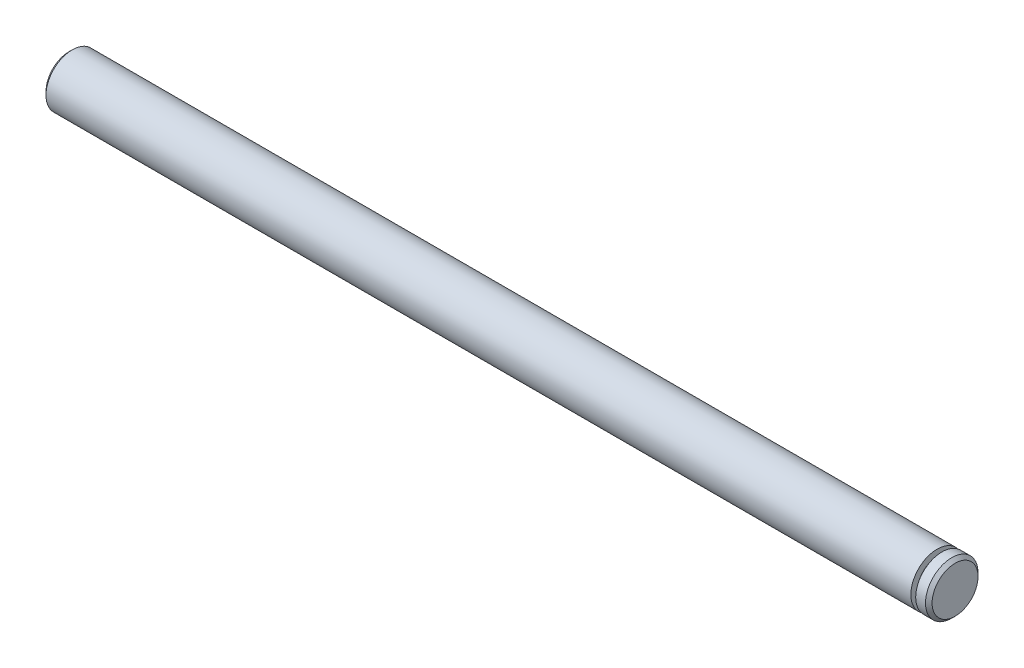
from build123d import *

# Parameters (mm, degrees)
CHAMFER1_SIZE = 0.5


with BuildPart() as part:
    # Sketch1 → Revolve1 (revolve)
    with BuildSketch(Plane.XY):
        Polygon((0.7366, 4), (2.7366, 4), (2.7366, 0), (-132.2634, 0), (-132.2634, 4), (0, 4), (0, 3), (0.7366, 3), align=None)
    revolve(axis=Axis((2.7366, 0, 0), (1, 0, 0)))

    # Chamfer1
    chamfer1_edges = [part.edges().sort_by_distance(p)[0] for p in [
        (-132.2634, -4, 0),
        (2.7366, -4, 0),
    ]]
    chamfer(chamfer1_edges, length=CHAMFER1_SIZE)


solid = part.part
